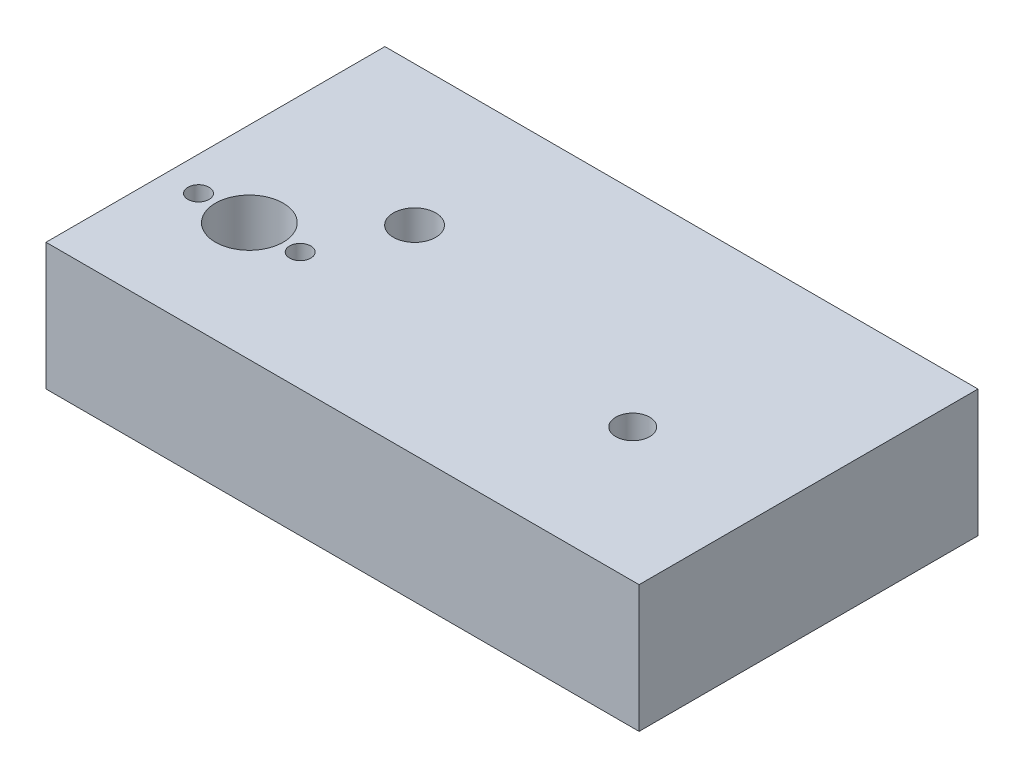
from build123d import *

# Parameters (mm, degrees)
SKETCH1_W                = 140
SKETCH1_H                = 30
BOSS_EXTRUDE1_DEPTH      = 80
SKETCH2_R                = 4.17592015
CUT_EXTRUDE1_DEPTH       = 15
LPATTERN1_COUNT          = 4
LPATTERN1_PITCH          = 110
SKETCH_1_R               = 25
CUT_EXTRUDE_1_DEPTH      = 10.5
SKETCH_2_R               = 5
CUT_EXTRUDE_2_DEPTH      = 10
CUT_EXTRUDE_2_DEPTH_BACK = 100
SKETCH_3_R               = 8
CUT_EXTRUDE_3_DEPTH      = 100
SKETCH_4_R               = 10
CUT_EXTRUDE_4_DEPTH      = 10.5
SKETCH_5_R               = 2.5
CUT_EXTRUDE_5_DEPTH      = 100
PATTERN_LINEAR_1_COUNT   = 2
PATTERN_LINEAR_1_PITCH   = 24
SKETCH_6_R               = 4
CUT_EXTRUDE_6_DEPTH      = 100


with BuildPart() as part:
    # Sketch1 → Boss-Extrude1 (new body)
    with BuildSketch(Plane.XY):
        with Locations((24.869684499, 8.141289438)):
            Rectangle(SKETCH1_W, SKETCH1_H)
    extrude(amount=BOSS_EXTRUDE1_DEPTH)

    # Sketch2 → Cut-Extrude1 (cut)
    with BuildSketch(Plane(origin=(0, 0, 0), x_dir=(-1, 0, 0), z_dir=(0, 0, -1))):
        with Locations((30.130315501, 7.814471991)):
            Circle(SKETCH2_R)
    cut_extrude1 = extrude(amount=-CUT_EXTRUDE1_DEPTH, mode=Mode.SUBTRACT)

    # LPattern1: Cut-Extrude1 ×4
    with Locations(*[(i * LPATTERN1_PITCH, 0, 0) for i in range(1, LPATTERN1_COUNT)]):
        add(cut_extrude1, mode=Mode.SUBTRACT)

    # Эскиз1 → Вырез-Вытянуть1 (cut)
    with BuildSketch(Plane.XZ.offset(6.858710562)):
        with Locations((-5.130315501, 33)):
            Circle(SKETCH_1_R)
    extrude(amount=-CUT_EXTRUDE_1_DEPTH, mode=Mode.SUBTRACT)

    # Эскиз2 → Вырез-Вытянуть2 (cut, two sides)
    with BuildSketch(Plane.XZ.offset(-3.641289438)) as cut_extrude_2_sk:
        with Locations((-5.130315501, 33)):
            Circle(SKETCH_2_R)
    extrude(amount=CUT_EXTRUDE_2_DEPTH, mode=Mode.SUBTRACT)
    extrude(cut_extrude_2_sk.sketch, amount=-CUT_EXTRUDE_2_DEPTH_BACK, mode=Mode.SUBTRACT)

    # Эскиз3 → Вырез-Вытянуть3 (cut)
    with BuildSketch(Plane.XZ.offset(6.858710562)):
        with Locations((-25.130315501, 52)):
            Circle(SKETCH_3_R)
    extrude(amount=-CUT_EXTRUDE_3_DEPTH, mode=Mode.SUBTRACT)

    # Эскиз4 → Вырез-Вытянуть4 (cut)
    with BuildSketch(Plane.XZ.offset(6.858710562)):
        with Locations((-25.130315501, 52)):
            Circle(SKETCH_4_R)
    extrude(amount=-CUT_EXTRUDE_4_DEPTH, mode=Mode.SUBTRACT)

    # Эскиз5 → Вырез-Вытянуть5 (cut)
    with BuildSketch(Plane(origin=(0, 23.141289438, 0), x_dir=(1, 0, 0), z_dir=(0, 1, 0))):
        with Locations((-37.130315501, -52)):
            Circle(SKETCH_5_R)
    cut_extrude_5 = extrude(amount=-CUT_EXTRUDE_5_DEPTH, mode=Mode.SUBTRACT)

    # Линейный массив1: Вырез-Вытянуть5 ×2
    with Locations(*[(i * PATTERN_LINEAR_1_PITCH, 0, 0) for i in range(1, PATTERN_LINEAR_1_COUNT)]):
        add(cut_extrude_5, mode=Mode.SUBTRACT)

    # Эскиз6 → Вырез-Вытянуть6 (cut)
    with BuildSketch(Plane(origin=(0, 23.141289438, 0), x_dir=(1, 0, 0), z_dir=(0, 1, 0))):
        with Locations((61.869684499, -48.5)):
            Circle(SKETCH_6_R)
    extrude(amount=-CUT_EXTRUDE_6_DEPTH, mode=Mode.SUBTRACT)


solid = part.part
